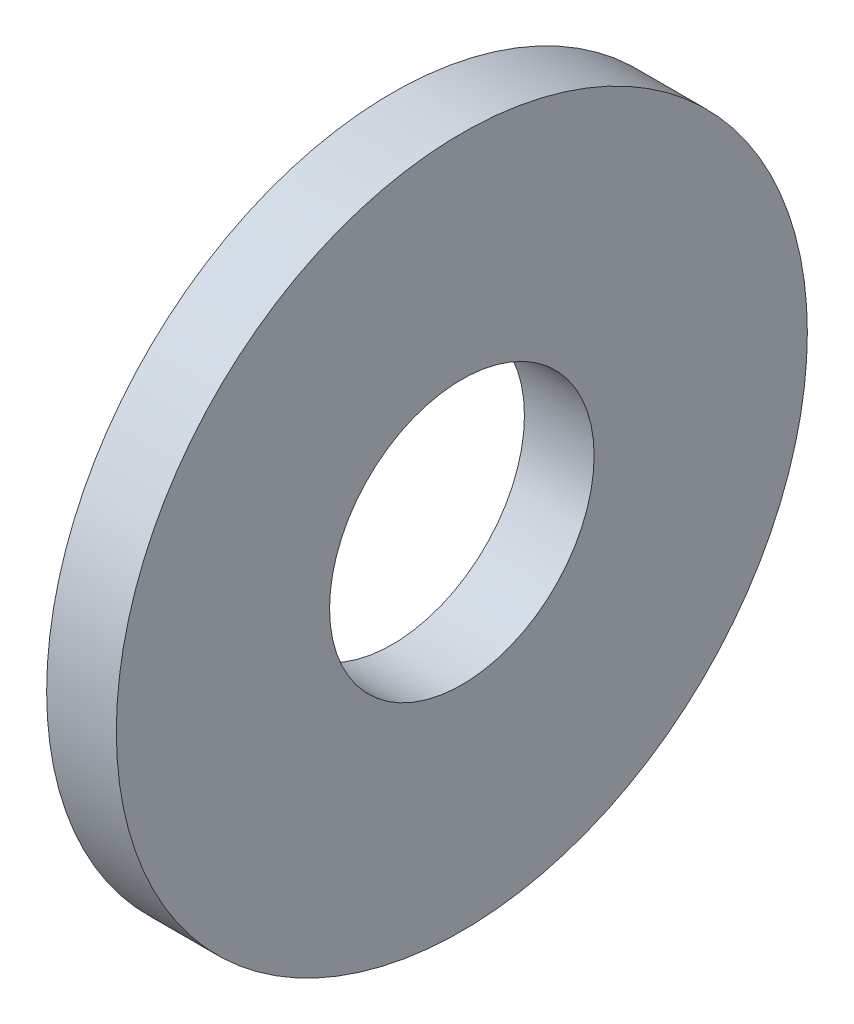
from build123d import *

# Parameters (mm, degrees)
SKETCH1_R           = 9.3218
SKETCH1_R_2         = 3.5687
BOSS_EXTRUDE1_DEPTH = 1.8796


with BuildPart() as part:
    # Sketch1 → Boss-Extrude1 (new body)
    with BuildSketch(Plane(origin=(0, 0, 0), x_dir=(0, 0, -1), z_dir=(1, 0, 0))):
        Circle(SKETCH1_R)
        Circle(SKETCH1_R_2, mode=Mode.SUBTRACT)
    extrude(amount=BOSS_EXTRUDE1_DEPTH)


solid = part.part
